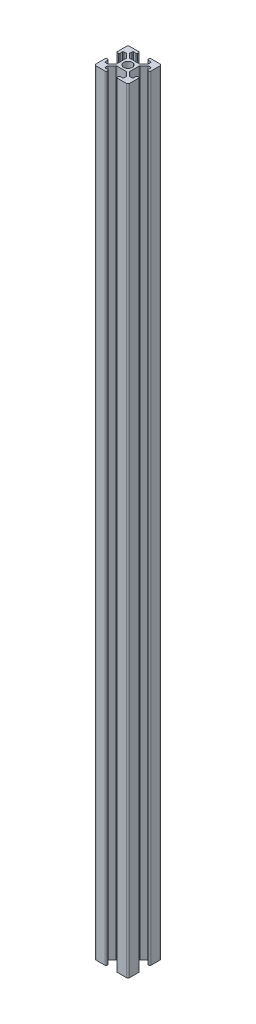
from build123d import *

# Parameters (mm, degrees)
SKETCH1_R           = 2.6
BOSS_EXTRUDE1_DEPTH = 460


with BuildPart() as part:
    # Sketch1 → Boss-Extrude1 (new body)
    with BuildSketch(Plane(origin=(0, 230, 0), x_dir=(1, 0, 0), z_dir=(0, 1, 0))):
        with BuildLine():
            Line((-3.1, 8.85), (-3.1, 9.5))
            ThreePointArc((-3.1, 9.5), (-3.246446609, 9.853553391), (-3.6, 10))
            Line((-3.6, 10), (-9, 10))
            ThreePointArc((-9, 10), (-9.707106781, 9.707106781), (-10, 9))
            Line((-10, 9), (-10, 3.6))
            ThreePointArc((-10, 3.6), (-9.853553391, 3.246446609), (-9.5, 3.1))
            Line((-9.5, 3.1), (-8.85, 3.1))
            ThreePointArc((-8.85, 3.1), (-8.496446609, 3.246446609), (-8.35, 3.6))
            Line((-8.35, 3.6), (-8.35, 5))
            ThreePointArc((-8.35, 5), (-8.203553391, 5.353553391), (-7.85, 5.5))
            Line((-7.85, 5.5), (-6.626345597, 5.5))
            ThreePointArc((-6.626345597, 5.5), (-6.435003881, 5.461939766), (-6.272792206, 5.353553391))
            Line((-6.272792206, 5.353553391), (-4.046446609, 3.127207794))
            ThreePointArc((-4.046446609, 3.127207794), (-3.938060234, 2.964996119), (-3.9, 2.773654403))
            Line((-3.9, 2.773654403), (-3.9, -2.773654403))
            ThreePointArc((-3.9, -2.773654403), (-3.938060234, -2.964996119), (-4.046446609, -3.127207794))
            Line((-4.046446609, -3.127207794), (-6.272792206, -5.353553391))
            ThreePointArc((-6.272792206, -5.353553391), (-6.435003881, -5.461939766), (-6.626345597, -5.5))
            Line((-6.626345597, -5.5), (-7.85, -5.5))
            ThreePointArc((-7.85, -5.5), (-8.203553391, -5.353553391), (-8.35, -5))
            Line((-8.35, -5), (-8.35, -3.6))
            ThreePointArc((-8.35, -3.6), (-8.496446609, -3.246446609), (-8.85, -3.1))
            Line((-8.85, -3.1), (-9.5, -3.1))
            ThreePointArc((-9.5, -3.1), (-9.853553391, -3.246446609), (-10, -3.6))
            Line((-10, -3.6), (-10, -9))
            ThreePointArc((-10, -9), (-9.707106781, -9.707106781), (-9, -10))
            Line((-9, -10), (-3.6, -10))
            ThreePointArc((-3.6, -10), (-3.246446609, -9.853553391), (-3.1, -9.5))
            Line((-3.1, -9.5), (-3.1, -8.85))
            ThreePointArc((-3.1, -8.85), (-3.246446609, -8.496446609), (-3.6, -8.35))
            Line((-3.6, -8.35), (-5, -8.35))
            ThreePointArc((-5, -8.35), (-5.353553391, -8.203553391), (-5.5, -7.85))
            Line((-5.5, -7.85), (-5.5, -6.626345597))
            ThreePointArc((-5.5, -6.626345597), (-5.461939766, -6.435003881), (-5.353553391, -6.272792206))
            Line((-5.353553391, -6.272792206), (-3.127207794, -4.046446609))
            ThreePointArc((-3.127207794, -4.046446609), (-2.964996119, -3.938060234), (-2.773654403, -3.9))
            Line((-2.773654403, -3.9), (2.773654403, -3.9))
            ThreePointArc((2.773654403, -3.9), (2.964996119, -3.938060234), (3.127207794, -4.046446609))
            Line((3.127207794, -4.046446609), (5.353553391, -6.272792206))
            ThreePointArc((5.353553391, -6.272792206), (5.461939766, -6.435003881), (5.5, -6.626345597))
            Line((5.5, -6.626345597), (5.5, -7.85))
            ThreePointArc((5.5, -7.85), (5.353553391, -8.203553391), (5, -8.35))
            Line((5, -8.35), (3.6, -8.35))
            ThreePointArc((3.6, -8.35), (3.246446609, -8.496446609), (3.1, -8.85))
            Line((3.1, -8.85), (3.1, -9.5))
            ThreePointArc((3.1, -9.5), (3.246446609, -9.853553391), (3.6, -10))
            Line((3.6, -10), (9, -10))
            ThreePointArc((9, -10), (9.707106781, -9.707106781), (10, -9))
            Line((10, -9), (10, -3.6))
            ThreePointArc((10, -3.6), (9.853553391, -3.246446609), (9.5, -3.1))
            Line((9.5, -3.1), (8.85, -3.1))
            ThreePointArc((8.85, -3.1), (8.496446609, -3.246446609), (8.35, -3.6))
            Line((8.35, -3.6), (8.35, -5))
            ThreePointArc((8.35, -5), (8.203553391, -5.353553391), (7.85, -5.5))
            Line((7.85, -5.5), (6.626345597, -5.5))
            ThreePointArc((6.626345597, -5.5), (6.435003881, -5.461939766), (6.272792206, -5.353553391))
            Line((6.272792206, -5.353553391), (4.046446609, -3.127207794))
            ThreePointArc((4.046446609, -3.127207794), (3.938060234, -2.964996119), (3.9, -2.773654403))
            Line((3.9, -2.773654403), (3.9, 2.773654403))
            ThreePointArc((3.9, 2.773654403), (3.938060234, 2.964996119), (4.046446609, 3.127207794))
            Line((4.046446609, 3.127207794), (6.272792206, 5.353553391))
            ThreePointArc((6.272792206, 5.353553391), (6.435003881, 5.461939766), (6.626345597, 5.5))
            Line((6.626345597, 5.5), (7.85, 5.5))
            ThreePointArc((7.85, 5.5), (8.203553391, 5.353553391), (8.35, 5))
            Line((8.35, 5), (8.35, 3.6))
            ThreePointArc((8.35, 3.6), (8.496446609, 3.246446609), (8.85, 3.1))
            Line((8.85, 3.1), (9.5, 3.1))
            ThreePointArc((9.5, 3.1), (9.853553391, 3.246446609), (10, 3.6))
            Line((10, 3.6), (10, 9))
            ThreePointArc((10, 9), (9.707106781, 9.707106781), (9, 10))
            Line((9, 10), (3.6, 10))
            ThreePointArc((3.6, 10), (3.246446609, 9.853553391), (3.1, 9.5))
            Line((3.1, 9.5), (3.1, 8.85))
            ThreePointArc((3.1, 8.85), (3.246446609, 8.496446609), (3.6, 8.35))
            Line((3.6, 8.35), (5, 8.35))
            ThreePointArc((5, 8.35), (5.353553391, 8.203553391), (5.5, 7.85))
            Line((5.5, 7.85), (5.5, 6.626345597))
            ThreePointArc((5.5, 6.626345597), (5.461939766, 6.435003881), (5.353553391, 6.272792206))
            Line((5.353553391, 6.272792206), (3.127207794, 4.046446609))
            ThreePointArc((3.127207794, 4.046446609), (2.964996119, 3.938060234), (2.773654403, 3.9))
            Line((2.773654403, 3.9), (-2.773654403, 3.9))
            ThreePointArc((-2.773654403, 3.9), (-2.964996119, 3.938060234), (-3.127207794, 4.046446609))
            Line((-3.127207794, 4.046446609), (-5.5, 6.419238816))
            Line((-5.5, 6.419238816), (-5.5, 7.85))
            ThreePointArc((-5.5, 7.85), (-5.353553391, 8.203553391), (-5, 8.35))
            Line((-5, 8.35), (-3.6, 8.35))
            ThreePointArc((-3.6, 8.35), (-3.246446609, 8.496446609), (-3.1, 8.85))
        make_face()
        Circle(SKETCH1_R, mode=Mode.SUBTRACT)
    extrude(amount=-BOSS_EXTRUDE1_DEPTH)


solid = part.part
